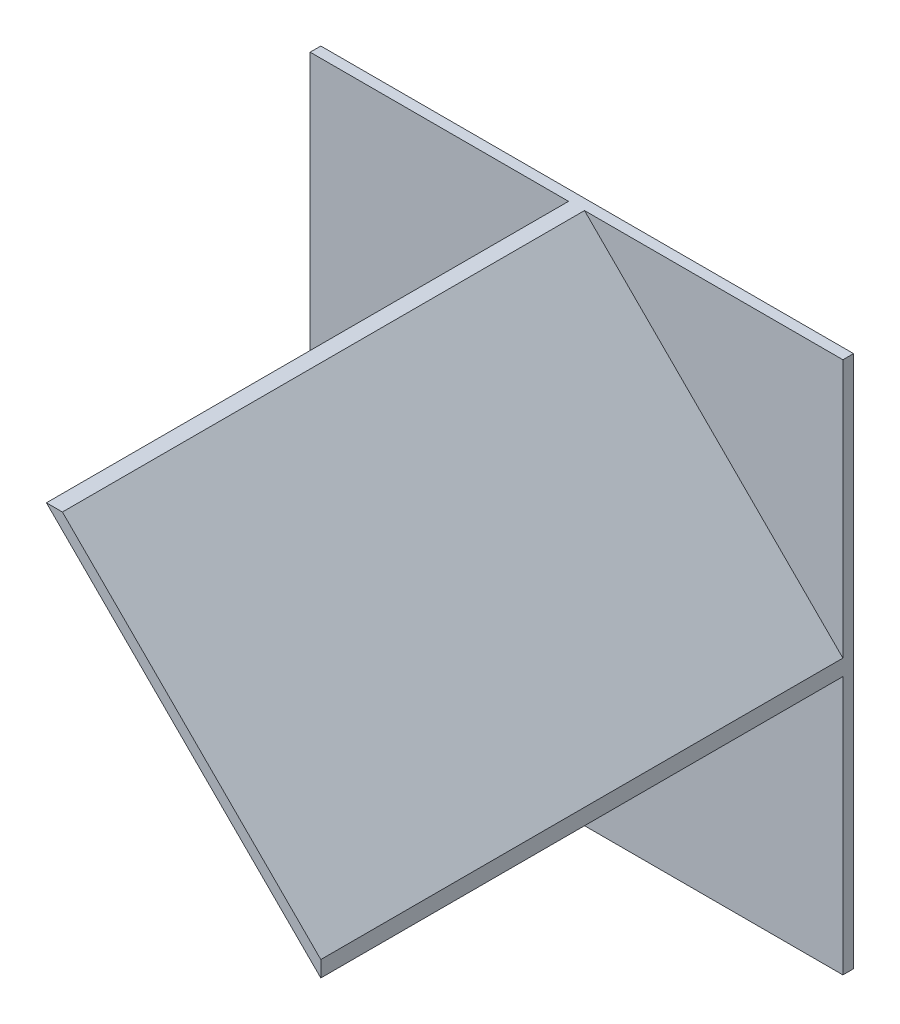
from build123d import *

# Parameters (mm, degrees)
SZKIC1_W                    = 100
SZKIC1_H                    = 100
DODANIE_WYCI_GNI_CIE1_DEPTH = 4
DODANIE_WYCI_GNI_CIE4_DEPTH = 196


with BuildPart() as part:
    # Szkic1 → Dodanie-wyciągnięcie1 (new body)
    with BuildSketch(Plane.XY):
        with Locations((-50, 50)):
            Rectangle(SZKIC1_W, SZKIC1_H)
        with Locations((50, 50)):
            Rectangle(SZKIC1_W, SZKIC1_H)
        with Locations((50, -50)):
            Rectangle(SZKIC1_W, SZKIC1_H)
        with Locations((-50, -50)):
            Rectangle(SZKIC1_W, SZKIC1_H)
    extrude(amount=DODANIE_WYCI_GNI_CIE1_DEPTH)

    # Szkic2 → Dodanie-wyciągnięcie4 (add)
    with BuildSketch(Plane.XY.offset(4)):
        Polygon((3, 100), (0, 100), (-3, 100), (100, -3), (100, 0), (100, 3), align=None)
    extrude(amount=DODANIE_WYCI_GNI_CIE4_DEPTH)


solid = part.part
